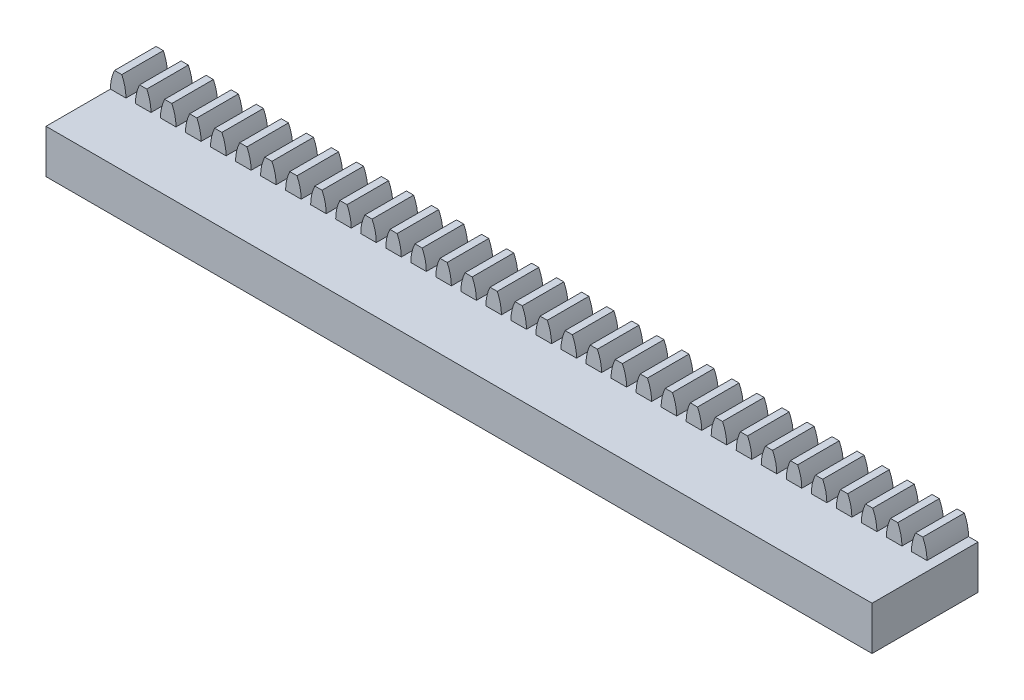
from build123d import *

# Parameters (mm, degrees)
RESSALTO_EXTRUS_O1_DEPTH      = 2
RESSALTO_EXTRUS_O1_2_DEPTH    = 2
RESSALTO_EXTRUS_O1_3_DEPTH    = 2
RESSALTO_EXTRUS_O1_4_DEPTH    = 2
RESSALTO_EXTRUS_O1_5_DEPTH    = 2
RESSALTO_EXTRUS_O1_6_DEPTH    = 2
RESSALTO_EXTRUS_O1_7_DEPTH    = 2
RESSALTO_EXTRUS_O1_8_DEPTH    = 2
RESSALTO_EXTRUS_O1_9_DEPTH    = 2
RESSALTO_EXTRUS_O1_10_DEPTH   = 2
RESSALTO_EXTRUS_O1_11_DEPTH   = 2
RESSALTO_EXTRUS_O1_12_DEPTH   = 2
RESSALTO_EXTRUS_O1_13_DEPTH   = 2
RESSALTO_EXTRUS_O1_14_DEPTH   = 2
RESSALTO_EXTRUS_O1_15_DEPTH   = 2
RESSALTO_EXTRUS_O1_16_DEPTH   = 2
RESSALTO_EXTRUS_O1_17_DEPTH   = 2
RESSALTO_EXTRUS_O1_18_DEPTH   = 2
RESSALTO_EXTRUS_O1_19_DEPTH   = 2
RESSALTO_EXTRUS_O1_20_DEPTH   = 2
RESSALTO_EXTRUS_O1_21_DEPTH   = 2
RESSALTO_EXTRUS_O1_22_DEPTH   = 2
RESSALTO_EXTRUS_O1_23_DEPTH   = 2
RESSALTO_EXTRUS_O1_24_DEPTH   = 2
RESSALTO_EXTRUS_O1_25_DEPTH   = 2
RESSALTO_EXTRUS_O1_26_DEPTH   = 2
RESSALTO_EXTRUS_O1_27_DEPTH   = 2
RESSALTO_EXTRUS_O1_28_DEPTH   = 2
RESSALTO_EXTRUS_O1_29_DEPTH   = 2
RESSALTO_EXTRUS_O1_30_DEPTH   = 2
RESSALTO_EXTRUS_O1_31_DEPTH   = 2
RESSALTO_EXTRUS_O1_32_DEPTH   = 2
RESSALTO_EXTRUS_O1_33_DEPTH   = 2
RESSALTO_EXTRUS_O2_DEPTH      = 8.2
RESSALTO_EXTRUS_O2_DEPTH_BACK = 2


with BuildPart() as part:
    # Esboço1 → Ressalto-extrusão1 (new, symmetric)
    with BuildSketch(Plane.XY):
        with BuildLine():
            Line((-1.017526261, 4.529689969), (-1.711247382, 4.529689969))
            ThreePointArc((-1.711247382, 4.529689969), (-2.010696446, 3.673045524), (-2.112202188, 2.771266155))
            Line((-2.112202188, 2.771266155), (-0.616571456, 2.771266155))
            ThreePointArc((-0.616571456, 2.771266155), (-0.718077198, 3.673045524), (-1.017526261, 4.529689969))
        make_face()
    extrude(amount=RESSALTO_EXTRUS_O1_DEPTH, both=True)



with BuildPart() as body_2:
    # Esboço1 → Ressalto-extrus_o1 2 (new, symmetric)
    with BuildSketch(Plane.XY):
        with BuildLine():
            ThreePointArc((0.698752618, 4.529689969), (0.399303554, 3.673045524), (0.297797812, 2.771266155))
            Line((0.297797812, 2.771266155), (1.793428544, 2.771266155))
            ThreePointArc((1.793428544, 2.771266155), (1.691922802, 3.673045524), (1.392473739, 4.529689969))
            Line((1.392473739, 4.529689969), (0.698752618, 4.529689969))
        make_face()
    extrude(amount=RESSALTO_EXTRUS_O1_2_DEPTH, both=True)


with BuildPart() as body_3:
    # Esboço1 → Ressalto-extrus_o1 3 (new, symmetric)
    with BuildSketch(Plane.XY):
        with BuildLine():
            ThreePointArc((3.108752618, 4.529689969), (2.809303554, 3.673045524), (2.707797812, 2.771266155))
            Line((2.707797812, 2.771266155), (4.203428544, 2.771266155))
            ThreePointArc((4.203428544, 2.771266155), (4.101922802, 3.673045524), (3.802473739, 4.529689969))
            Line((3.802473739, 4.529689969), (3.108752618, 4.529689969))
        make_face()
    extrude(amount=RESSALTO_EXTRUS_O1_3_DEPTH, both=True)


with BuildPart() as body_4:
    # Esboço1 → Ressalto-extrus_o1 4 (new, symmetric)
    with BuildSketch(Plane.XY):
        with BuildLine():
            Line((75.007797812, 2.771266155), (76.503428544, 2.771266155))
            ThreePointArc((76.503428544, 2.771266155), (76.401922802, 3.673045524), (76.102473739, 4.529689969))
            Line((76.102473739, 4.529689969), (75.408752618, 4.529689969))
            ThreePointArc((75.408752618, 4.529689969), (75.109303554, 3.673045524), (75.007797812, 2.771266155))
        make_face()
    extrude(amount=RESSALTO_EXTRUS_O1_4_DEPTH, both=True)


with BuildPart() as body_5:
    # Esboço1 → Ressalto-extrus_o1 5 (new, symmetric)
    with BuildSketch(Plane.XY):
        with BuildLine():
            ThreePointArc((5.518752618, 4.529689969), (5.219303554, 3.673045524), (5.117797812, 2.771266155))
            Line((5.117797812, 2.771266155), (6.613428544, 2.771266155))
            ThreePointArc((6.613428544, 2.771266155), (6.511922802, 3.673045524), (6.212473739, 4.529689969))
            Line((6.212473739, 4.529689969), (5.518752618, 4.529689969))
        make_face()
    extrude(amount=RESSALTO_EXTRUS_O1_5_DEPTH, both=True)


with BuildPart() as body_6:
    # Esboço1 → Ressalto-extrus_o1 6 (new, symmetric)
    with BuildSketch(Plane.XY):
        with BuildLine():
            Line((72.597797812, 2.771266155), (74.093428544, 2.771266155))
            ThreePointArc((74.093428544, 2.771266155), (73.991922802, 3.673045524), (73.692473739, 4.529689969))
            Line((73.692473739, 4.529689969), (72.998752618, 4.529689969))
            ThreePointArc((72.998752618, 4.529689969), (72.699303554, 3.673045524), (72.597797812, 2.771266155))
        make_face()
    extrude(amount=RESSALTO_EXTRUS_O1_6_DEPTH, both=True)


with BuildPart() as body_7:
    # Esboço1 → Ressalto-extrus_o1 7 (new, symmetric)
    with BuildSketch(Plane.XY):
        with BuildLine():
            ThreePointArc((7.928752618, 4.529689969), (7.629303554, 3.673045524), (7.527797812, 2.771266155))
            Line((7.527797812, 2.771266155), (9.023428544, 2.771266155))
            ThreePointArc((9.023428544, 2.771266155), (8.921922802, 3.673045524), (8.622473739, 4.529689969))
            Line((8.622473739, 4.529689969), (7.928752618, 4.529689969))
        make_face()
    extrude(amount=RESSALTO_EXTRUS_O1_7_DEPTH, both=True)


with BuildPart() as body_8:
    # Esboço1 → Ressalto-extrus_o1 8 (new, symmetric)
    with BuildSketch(Plane.XY):
        with BuildLine():
            Line((70.187797812, 2.771266155), (71.683428544, 2.771266155))
            ThreePointArc((71.683428544, 2.771266155), (71.581922802, 3.673045524), (71.282473739, 4.529689969))
            Line((71.282473739, 4.529689969), (70.588752618, 4.529689969))
            ThreePointArc((70.588752618, 4.529689969), (70.289303554, 3.673045524), (70.187797812, 2.771266155))
        make_face()
    extrude(amount=RESSALTO_EXTRUS_O1_8_DEPTH, both=True)


with BuildPart() as body_9:
    # Esboço1 → Ressalto-extrus_o1 9 (new, symmetric)
    with BuildSketch(Plane.XY):
        with BuildLine():
            ThreePointArc((10.338752618, 4.529689969), (10.039303554, 3.673045524), (9.937797812, 2.771266155))
            Line((9.937797812, 2.771266155), (11.433428544, 2.771266155))
            ThreePointArc((11.433428544, 2.771266155), (11.331922802, 3.673045524), (11.032473739, 4.529689969))
            Line((11.032473739, 4.529689969), (10.338752618, 4.529689969))
        make_face()
    extrude(amount=RESSALTO_EXTRUS_O1_9_DEPTH, both=True)


with BuildPart() as body_10:
    # Esboço1 → Ressalto-extrus_o1 10 (new, symmetric)
    with BuildSketch(Plane.XY):
        with BuildLine():
            Line((67.777797812, 2.771266155), (69.273428544, 2.771266155))
            ThreePointArc((69.273428544, 2.771266155), (69.171922802, 3.673045524), (68.872473739, 4.529689969))
            Line((68.872473739, 4.529689969), (68.178752618, 4.529689969))
            ThreePointArc((68.178752618, 4.529689969), (67.879303554, 3.673045524), (67.777797812, 2.771266155))
        make_face()
    extrude(amount=RESSALTO_EXTRUS_O1_10_DEPTH, both=True)


with BuildPart() as body_11:
    # Esboço1 → Ressalto-extrus_o1 11 (new, symmetric)
    with BuildSketch(Plane.XY):
        with BuildLine():
            ThreePointArc((12.748752618, 4.529689969), (12.449303554, 3.673045524), (12.347797812, 2.771266155))
            Line((12.347797812, 2.771266155), (13.843428544, 2.771266155))
            ThreePointArc((13.843428544, 2.771266155), (13.741922802, 3.673045524), (13.442473739, 4.529689969))
            Line((13.442473739, 4.529689969), (12.748752618, 4.529689969))
        make_face()
    extrude(amount=RESSALTO_EXTRUS_O1_11_DEPTH, both=True)


with BuildPart() as body_12:
    # Esboço1 → Ressalto-extrus_o1 12 (new, symmetric)
    with BuildSketch(Plane.XY):
        with BuildLine():
            Line((65.367797812, 2.771266155), (66.863428544, 2.771266155))
            ThreePointArc((66.863428544, 2.771266155), (66.761922802, 3.673045524), (66.462473739, 4.529689969))
            Line((66.462473739, 4.529689969), (65.768752618, 4.529689969))
            ThreePointArc((65.768752618, 4.529689969), (65.469303554, 3.673045524), (65.367797812, 2.771266155))
        make_face()
    extrude(amount=RESSALTO_EXTRUS_O1_12_DEPTH, both=True)


with BuildPart() as body_13:
    # Esboço1 → Ressalto-extrus_o1 13 (new, symmetric)
    with BuildSketch(Plane.XY):
        with BuildLine():
            ThreePointArc((15.158752618, 4.529689969), (14.859303554, 3.673045524), (14.757797812, 2.771266155))
            Line((14.757797812, 2.771266155), (16.253428544, 2.771266155))
            ThreePointArc((16.253428544, 2.771266155), (16.151922802, 3.673045524), (15.852473739, 4.529689969))
            Line((15.852473739, 4.529689969), (15.158752618, 4.529689969))
        make_face()
    extrude(amount=RESSALTO_EXTRUS_O1_13_DEPTH, both=True)


with BuildPart() as body_14:
    # Esboço1 → Ressalto-extrus_o1 14 (new, symmetric)
    with BuildSketch(Plane.XY):
        with BuildLine():
            Line((62.957797812, 2.771266155), (64.453428544, 2.771266155))
            ThreePointArc((64.453428544, 2.771266155), (64.351922802, 3.673045524), (64.052473739, 4.529689969))
            Line((64.052473739, 4.529689969), (63.358752618, 4.529689969))
            ThreePointArc((63.358752618, 4.529689969), (63.059303554, 3.673045524), (62.957797812, 2.771266155))
        make_face()
    extrude(amount=RESSALTO_EXTRUS_O1_14_DEPTH, both=True)


with BuildPart() as body_15:
    # Esboço1 → Ressalto-extrus_o1 15 (new, symmetric)
    with BuildSketch(Plane.XY):
        with BuildLine():
            ThreePointArc((17.568752618, 4.529689969), (17.269303554, 3.673045524), (17.167797812, 2.771266155))
            Line((17.167797812, 2.771266155), (18.663428544, 2.771266155))
            ThreePointArc((18.663428544, 2.771266155), (18.561922802, 3.673045524), (18.262473739, 4.529689969))
            Line((18.262473739, 4.529689969), (17.568752618, 4.529689969))
        make_face()
    extrude(amount=RESSALTO_EXTRUS_O1_15_DEPTH, both=True)


with BuildPart() as body_16:
    # Esboço1 → Ressalto-extrus_o1 16 (new, symmetric)
    with BuildSketch(Plane.XY):
        with BuildLine():
            Line((60.547797812, 2.771266155), (62.043428544, 2.771266155))
            ThreePointArc((62.043428544, 2.771266155), (61.941922802, 3.673045524), (61.642473739, 4.529689969))
            Line((61.642473739, 4.529689969), (60.948752618, 4.529689969))
            ThreePointArc((60.948752618, 4.529689969), (60.649303554, 3.673045524), (60.547797812, 2.771266155))
        make_face()
    extrude(amount=RESSALTO_EXTRUS_O1_16_DEPTH, both=True)


with BuildPart() as body_17:
    # Esboço1 → Ressalto-extrus_o1 17 (new, symmetric)
    with BuildSketch(Plane.XY):
        with BuildLine():
            ThreePointArc((19.978752618, 4.529689969), (19.679303554, 3.673045524), (19.577797812, 2.771266155))
            Line((19.577797812, 2.771266155), (21.073428544, 2.771266155))
            ThreePointArc((21.073428544, 2.771266155), (20.971922802, 3.673045524), (20.672473739, 4.529689969))
            Line((20.672473739, 4.529689969), (19.978752618, 4.529689969))
        make_face()
    extrude(amount=RESSALTO_EXTRUS_O1_17_DEPTH, both=True)


with BuildPart() as body_18:
    # Esboço1 → Ressalto-extrus_o1 18 (new, symmetric)
    with BuildSketch(Plane.XY):
        with BuildLine():
            Line((58.137797812, 2.771266155), (59.633428544, 2.771266155))
            ThreePointArc((59.633428544, 2.771266155), (59.531922802, 3.673045524), (59.232473739, 4.529689969))
            Line((59.232473739, 4.529689969), (58.538752618, 4.529689969))
            ThreePointArc((58.538752618, 4.529689969), (58.239303554, 3.673045524), (58.137797812, 2.771266155))
        make_face()
    extrude(amount=RESSALTO_EXTRUS_O1_18_DEPTH, both=True)


with BuildPart() as body_19:
    # Esboço1 → Ressalto-extrus_o1 19 (new, symmetric)
    with BuildSketch(Plane.XY):
        with BuildLine():
            ThreePointArc((22.388752618, 4.529689969), (22.089303554, 3.673045524), (21.987797812, 2.771266155))
            Line((21.987797812, 2.771266155), (23.483428544, 2.771266155))
            ThreePointArc((23.483428544, 2.771266155), (23.381922802, 3.673045524), (23.082473739, 4.529689969))
            Line((23.082473739, 4.529689969), (22.388752618, 4.529689969))
        make_face()
    extrude(amount=RESSALTO_EXTRUS_O1_19_DEPTH, both=True)


with BuildPart() as body_20:
    # Esboço1 → Ressalto-extrus_o1 20 (new, symmetric)
    with BuildSketch(Plane.XY):
        with BuildLine():
            Line((55.727797812, 2.771266155), (57.223428544, 2.771266155))
            ThreePointArc((57.223428544, 2.771266155), (57.121922802, 3.673045524), (56.822473739, 4.529689969))
            Line((56.822473739, 4.529689969), (56.128752618, 4.529689969))
            ThreePointArc((56.128752618, 4.529689969), (55.829303554, 3.673045524), (55.727797812, 2.771266155))
        make_face()
    extrude(amount=RESSALTO_EXTRUS_O1_20_DEPTH, both=True)


with BuildPart() as body_21:
    # Esboço1 → Ressalto-extrus_o1 21 (new, symmetric)
    with BuildSketch(Plane.XY):
        with BuildLine():
            ThreePointArc((24.798752618, 4.529689969), (24.499303554, 3.673045524), (24.397797812, 2.771266155))
            Line((24.397797812, 2.771266155), (25.893428544, 2.771266155))
            ThreePointArc((25.893428544, 2.771266155), (25.791922802, 3.673045524), (25.492473739, 4.529689969))
            Line((25.492473739, 4.529689969), (24.798752618, 4.529689969))
        make_face()
    extrude(amount=RESSALTO_EXTRUS_O1_21_DEPTH, both=True)


with BuildPart() as body_22:
    # Esboço1 → Ressalto-extrus_o1 22 (new, symmetric)
    with BuildSketch(Plane.XY):
        with BuildLine():
            Line((53.317797812, 2.771266155), (54.813428544, 2.771266155))
            ThreePointArc((54.813428544, 2.771266155), (54.711922802, 3.673045524), (54.412473739, 4.529689969))
            Line((54.412473739, 4.529689969), (53.718752618, 4.529689969))
            ThreePointArc((53.718752618, 4.529689969), (53.419303554, 3.673045524), (53.317797812, 2.771266155))
        make_face()
    extrude(amount=RESSALTO_EXTRUS_O1_22_DEPTH, both=True)


with BuildPart() as body_23:
    # Esboço1 → Ressalto-extrus_o1 23 (new, symmetric)
    with BuildSketch(Plane.XY):
        with BuildLine():
            ThreePointArc((27.208752618, 4.529689969), (26.909303554, 3.673045524), (26.807797812, 2.771266155))
            Line((26.807797812, 2.771266155), (28.303428544, 2.771266155))
            ThreePointArc((28.303428544, 2.771266155), (28.201922802, 3.673045524), (27.902473739, 4.529689969))
            Line((27.902473739, 4.529689969), (27.208752618, 4.529689969))
        make_face()
    extrude(amount=RESSALTO_EXTRUS_O1_23_DEPTH, both=True)


with BuildPart() as body_24:
    # Esboço1 → Ressalto-extrus_o1 24 (new, symmetric)
    with BuildSketch(Plane.XY):
        with BuildLine():
            Line((50.907797812, 2.771266155), (52.403428544, 2.771266155))
            ThreePointArc((52.403428544, 2.771266155), (52.301922802, 3.673045524), (52.002473739, 4.529689969))
            Line((52.002473739, 4.529689969), (51.308752618, 4.529689969))
            ThreePointArc((51.308752618, 4.529689969), (51.009303554, 3.673045524), (50.907797812, 2.771266155))
        make_face()
    extrude(amount=RESSALTO_EXTRUS_O1_24_DEPTH, both=True)


with BuildPart() as body_25:
    # Esboço1 → Ressalto-extrus_o1 25 (new, symmetric)
    with BuildSketch(Plane.XY):
        with BuildLine():
            ThreePointArc((29.618752618, 4.529689969), (29.319303554, 3.673045524), (29.217797812, 2.771266155))
            Line((29.217797812, 2.771266155), (30.713428544, 2.771266155))
            ThreePointArc((30.713428544, 2.771266155), (30.611922802, 3.673045524), (30.312473739, 4.529689969))
            Line((30.312473739, 4.529689969), (29.618752618, 4.529689969))
        make_face()
    extrude(amount=RESSALTO_EXTRUS_O1_25_DEPTH, both=True)


with BuildPart() as body_26:
    # Esboço1 → Ressalto-extrus_o1 26 (new, symmetric)
    with BuildSketch(Plane.XY):
        with BuildLine():
            Line((48.497797812, 2.771266155), (49.993428544, 2.771266155))
            ThreePointArc((49.993428544, 2.771266155), (49.891922802, 3.673045524), (49.592473739, 4.529689969))
            Line((49.592473739, 4.529689969), (48.898752618, 4.529689969))
            ThreePointArc((48.898752618, 4.529689969), (48.599303554, 3.673045524), (48.497797812, 2.771266155))
        make_face()
    extrude(amount=RESSALTO_EXTRUS_O1_26_DEPTH, both=True)


with BuildPart() as body_27:
    # Esboço1 → Ressalto-extrus_o1 27 (new, symmetric)
    with BuildSketch(Plane.XY):
        with BuildLine():
            ThreePointArc((32.028752618, 4.529689969), (31.729303554, 3.673045524), (31.627797812, 2.771266155))
            Line((31.627797812, 2.771266155), (33.123428544, 2.771266155))
            ThreePointArc((33.123428544, 2.771266155), (33.021922802, 3.673045524), (32.722473739, 4.529689969))
            Line((32.722473739, 4.529689969), (32.028752618, 4.529689969))
        make_face()
    extrude(amount=RESSALTO_EXTRUS_O1_27_DEPTH, both=True)


with BuildPart() as body_28:
    # Esboço1 → Ressalto-extrus_o1 28 (new, symmetric)
    with BuildSketch(Plane.XY):
        with BuildLine():
            Line((46.087797812, 2.771266155), (47.583428544, 2.771266155))
            ThreePointArc((47.583428544, 2.771266155), (47.481922802, 3.673045524), (47.182473739, 4.529689969))
            Line((47.182473739, 4.529689969), (46.488752618, 4.529689969))
            ThreePointArc((46.488752618, 4.529689969), (46.189303554, 3.673045524), (46.087797812, 2.771266155))
        make_face()
    extrude(amount=RESSALTO_EXTRUS_O1_28_DEPTH, both=True)


with BuildPart() as body_29:
    # Esboço1 → Ressalto-extrus_o1 29 (new, symmetric)
    with BuildSketch(Plane.XY):
        with BuildLine():
            ThreePointArc((34.438752618, 4.529689969), (34.139303554, 3.673045524), (34.037797812, 2.771266155))
            Line((34.037797812, 2.771266155), (35.533428544, 2.771266155))
            ThreePointArc((35.533428544, 2.771266155), (35.431922802, 3.673045524), (35.132473739, 4.529689969))
            Line((35.132473739, 4.529689969), (34.438752618, 4.529689969))
        make_face()
    extrude(amount=RESSALTO_EXTRUS_O1_29_DEPTH, both=True)


with BuildPart() as body_30:
    # Esboço1 → Ressalto-extrus_o1 30 (new, symmetric)
    with BuildSketch(Plane.XY):
        with BuildLine():
            Line((43.677797812, 2.771266155), (45.173428544, 2.771266155))
            ThreePointArc((45.173428544, 2.771266155), (45.071922802, 3.673045524), (44.772473739, 4.529689969))
            Line((44.772473739, 4.529689969), (44.078752618, 4.529689969))
            ThreePointArc((44.078752618, 4.529689969), (43.779303554, 3.673045524), (43.677797812, 2.771266155))
        make_face()
    extrude(amount=RESSALTO_EXTRUS_O1_30_DEPTH, both=True)


with BuildPart() as body_31:
    # Esboço1 → Ressalto-extrus_o1 31 (new, symmetric)
    with BuildSketch(Plane.XY):
        with BuildLine():
            ThreePointArc((36.848752618, 4.529689969), (36.549303554, 3.673045524), (36.447797812, 2.771266155))
            Line((36.447797812, 2.771266155), (37.943428544, 2.771266155))
            ThreePointArc((37.943428544, 2.771266155), (37.841922802, 3.673045524), (37.542473739, 4.529689969))
            Line((37.542473739, 4.529689969), (36.848752618, 4.529689969))
        make_face()
    extrude(amount=RESSALTO_EXTRUS_O1_31_DEPTH, both=True)


with BuildPart() as body_32:
    # Esboço1 → Ressalto-extrus_o1 32 (new, symmetric)
    with BuildSketch(Plane.XY):
        with BuildLine():
            Line((41.267797812, 2.771266155), (42.763428544, 2.771266155))
            ThreePointArc((42.763428544, 2.771266155), (42.661922802, 3.673045524), (42.362473739, 4.529689969))
            Line((42.362473739, 4.529689969), (41.668752618, 4.529689969))
            ThreePointArc((41.668752618, 4.529689969), (41.369303554, 3.673045524), (41.267797812, 2.771266155))
        make_face()
    extrude(amount=RESSALTO_EXTRUS_O1_32_DEPTH, both=True)


with BuildPart() as body_33:
    # Esboço1 → Ressalto-extrus_o1 33 (new, symmetric)
    with BuildSketch(Plane.XY):
        with BuildLine():
            ThreePointArc((39.258752618, 4.529689969), (38.959303554, 3.673045524), (38.857797812, 2.771266155))
            Line((38.857797812, 2.771266155), (40.353428544, 2.771266155))
            ThreePointArc((40.353428544, 2.771266155), (40.251922802, 3.673045524), (39.952473739, 4.529689969))
            Line((39.952473739, 4.529689969), (39.258752618, 4.529689969))
        make_face()
    extrude(amount=RESSALTO_EXTRUS_O1_33_DEPTH, both=True)


with BuildPart() as part_1:
    add(part.part)

    add(body_2.part)  # Ressalto-extrusão2 merges body 2

    add(body_3.part)  # Ressalto-extrusão2 merges body 3

    add(body_5.part)  # Ressalto-extrusão2 merges body 5

    add(body_7.part)  # Ressalto-extrusão2 merges body 7

    add(body_9.part)  # Ressalto-extrusão2 merges body 9

    add(body_11.part)  # Ressalto-extrusão2 merges body 11

    add(body_13.part)  # Ressalto-extrusão2 merges body 13

    add(body_15.part)  # Ressalto-extrusão2 merges body 15

    add(body_17.part)  # Ressalto-extrusão2 merges body 17

    add(body_19.part)  # Ressalto-extrusão2 merges body 19

    add(body_21.part)  # Ressalto-extrusão2 merges body 21

    add(body_23.part)  # Ressalto-extrusão2 merges body 23

    add(body_25.part)  # Ressalto-extrusão2 merges body 25

    add(body_27.part)  # Ressalto-extrusão2 merges body 27

    add(body_29.part)  # Ressalto-extrusão2 merges body 29

    add(body_31.part)  # Ressalto-extrusão2 merges body 31

    add(body_33.part)  # Ressalto-extrusão2 merges body 33

    add(body_32.part)  # Ressalto-extrusão2 merges body 32

    add(body_30.part)  # Ressalto-extrusão2 merges body 30

    add(body_28.part)  # Ressalto-extrusão2 merges body 28
    # Esboço1<7> → Ressalto-extrusão2 (add, two sides: drawn at the far end of the back side and taken through both)
    with BuildSketch(Plane.XY.offset(-RESSALTO_EXTRUS_O2_DEPTH_BACK)):
        Polygon((-0.616571456, 2.771266155), (-2.112202188, 2.771266155), (-2.112202188, -1.428733845), (47.887797812, -1.428733845), (77.417797812, -1.428733845), (77.417797812, 2.771266155), (76.503428544, 2.771266155), (75.007797812, 2.771266155), (74.093428544, 2.771266155), (72.597797812, 2.771266155), (71.683428544, 2.771266155), (70.187797812, 2.771266155), (69.273428544, 2.771266155), (67.777797812, 2.771266155), (66.863428544, 2.771266155), (65.367797812, 2.771266155), (64.453428544, 2.771266155), (62.957797812, 2.771266155), (62.043428544, 2.771266155), (60.547797812, 2.771266155), (59.633428544, 2.771266155), (58.137797812, 2.771266155), (57.223428544, 2.771266155), (55.727797812, 2.771266155), (54.813428544, 2.771266155), (53.317797812, 2.771266155), (52.403428544, 2.771266155), (50.907797812, 2.771266155), (49.993428544, 2.771266155), (48.497797812, 2.771266155), (47.583428544, 2.771266155), (46.087797812, 2.771266155), (45.173428544, 2.771266155), (43.677797812, 2.771266155), (42.763428544, 2.771266155), (41.267797812, 2.771266155), (40.353428544, 2.771266155), (38.857797812, 2.771266155), (37.943428544, 2.771266155), (36.447797812, 2.771266155), (35.533428544, 2.771266155), (34.037797812, 2.771266155), (33.123428544, 2.771266155), (31.627797812, 2.771266155), (30.713428544, 2.771266155), (29.217797812, 2.771266155), (28.303428544, 2.771266155), (26.807797812, 2.771266155), (25.893428544, 2.771266155), (24.397797812, 2.771266155), (23.483428544, 2.771266155), (21.987797812, 2.771266155), (21.073428544, 2.771266155), (19.577797812, 2.771266155), (18.663428544, 2.771266155), (17.167797812, 2.771266155), (16.253428544, 2.771266155), (14.757797812, 2.771266155), (13.843428544, 2.771266155), (12.347797812, 2.771266155), (11.433428544, 2.771266155), (9.937797812, 2.771266155), (9.023428544, 2.771266155), (7.527797812, 2.771266155), (6.613428544, 2.771266155), (5.117797812, 2.771266155), (4.203428544, 2.771266155), (2.707797812, 2.771266155), (1.793428544, 2.771266155), (0.297797812, 2.771266155), align=None)
    extrude(amount=RESSALTO_EXTRUS_O2_DEPTH + RESSALTO_EXTRUS_O2_DEPTH_BACK)


solid = Compound([body_4.part, body_6.part, body_8.part, body_10.part, body_12.part, body_14.part, body_16.part, body_18.part, body_20.part, body_22.part, body_24.part, body_26.part, part_1.part])
